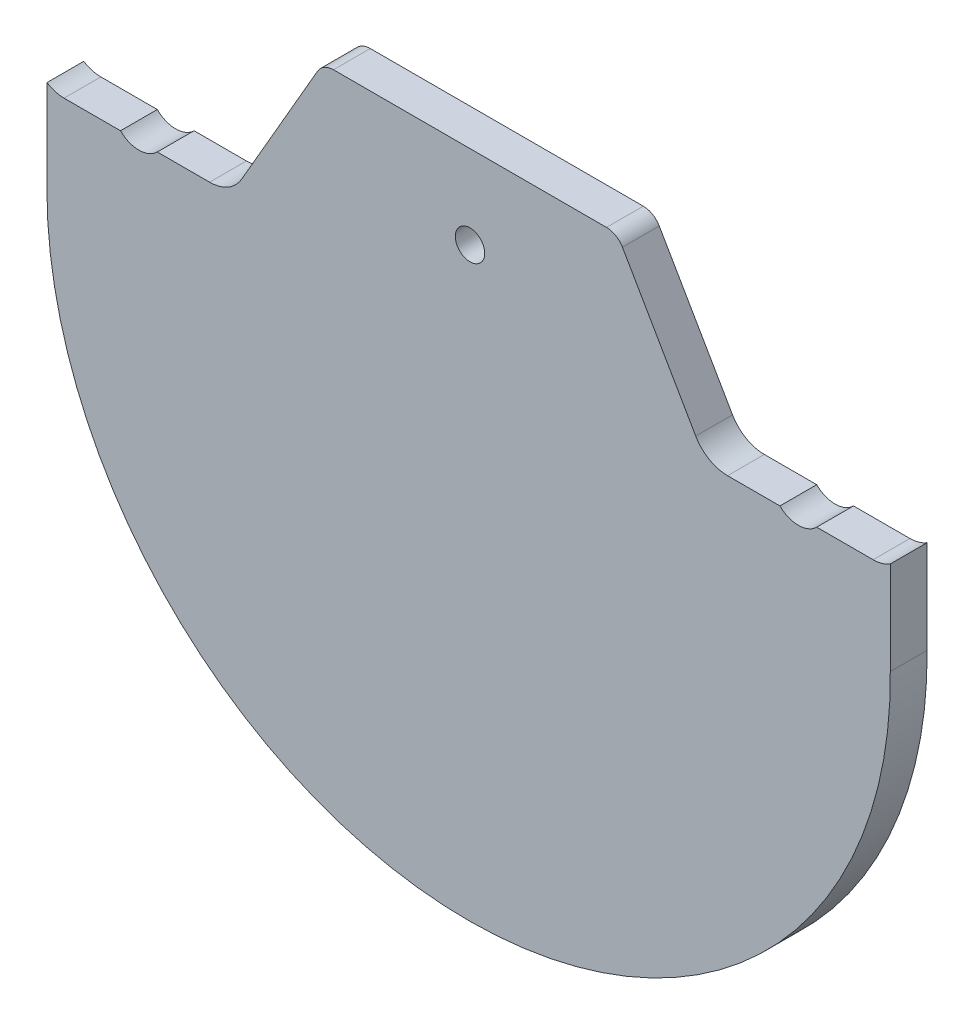
from build123d import *

# Parameters (mm, degrees)
AUFSATZ_LINEAR_AUSTRAGEN1_DEPTH    = 5
F_4_0_4_DURCHMESSER_BOHRUNG1_D     = 4
F_4_0_4_DURCHMESSER_BOHRUNG1_DEPTH = 5
F_4_0_4_DURCHMESSER_BOHRUNG1_TIP   = 1.201721238


with BuildPart() as part:
    # Skizze2 → Aufsatz-Linear austragen1 (new body)
    with BuildSketch(Plane.XY):
        with BuildLine():
            Line((1.443375673, 0), (38.556624327, 0))
            ThreePointArc((38.556624327, 0), (39.806624327, -0.334936491), (40.721687836, -1.25))
            Line((40.721687836, -1.25), (50.680145631, -18.498554865))
            ThreePointArc((50.680145631, -18.498554865), (52.51027265, -20.328681884), (55.01027265, -20.998554865))
            Line((55.01027265, -20.998554865), (62.123521304, -20.998554865))
            ThreePointArc((62.123521304, -20.998554865), (64.623521304, -22.034088771), (67.123521304, -20.998554865))
            Line((67.123521304, -20.998554865), (74.793302349, -20.998554865))
            ThreePointArc((74.793302349, -20.998554865), (76.005598743, -20.827762698), (77.123521304, -20.328681884))
            Line((77.123521304, -20.328681884), (77.123521304, -32.998554865))
            ThreePointArc((77.123521304, -32.998554865), (20.139660848, -90.963323142), (-37.5, -33.650635095))
            Line((-37.5, -33.650635095), (-37.501029815, -20.980635095))
            ThreePointArc((-37.501029815, -20.980635095), (-36.382703591, -21.479811555), (-35.17, -21.650635095))
            Line((-35.17, -21.650635095), (-27.5, -21.650635095))
            ThreePointArc((-27.5, -21.650635095), (-25, -22.686169001), (-22.5, -21.650635095))
            Line((-22.5, -21.650635095), (-15.386751346, -21.650635095))
            ThreePointArc((-15.386751346, -21.650635095), (-12.886751346, -20.980762114), (-11.056624327, -19.150635095))
            Line((-11.056624327, -19.150635095), (-0.721687836, -1.25))
            ThreePointArc((-0.721687836, -1.25), (0.193375673, -0.334936491), (1.443375673, 0))
        make_face()
    extrude(amount=AUFSATZ_LINEAR_AUSTRAGEN1_DEPTH)

    # Ø4.0 (4) Durchmesser Bohrung1
    with Locations(Plane.XY.offset(5)):
        with Locations((20, -11.330104149)):
            Hole(F_4_0_4_DURCHMESSER_BOHRUNG1_D / 2, depth=F_4_0_4_DURCHMESSER_BOHRUNG1_DEPTH)
            with Locations((0, 0, -(F_4_0_4_DURCHMESSER_BOHRUNG1_DEPTH + F_4_0_4_DURCHMESSER_BOHRUNG1_TIP / 2))):  # 118° drill point
                Cone(0, F_4_0_4_DURCHMESSER_BOHRUNG1_D / 2, F_4_0_4_DURCHMESSER_BOHRUNG1_TIP, mode=Mode.SUBTRACT)


solid = part.part
